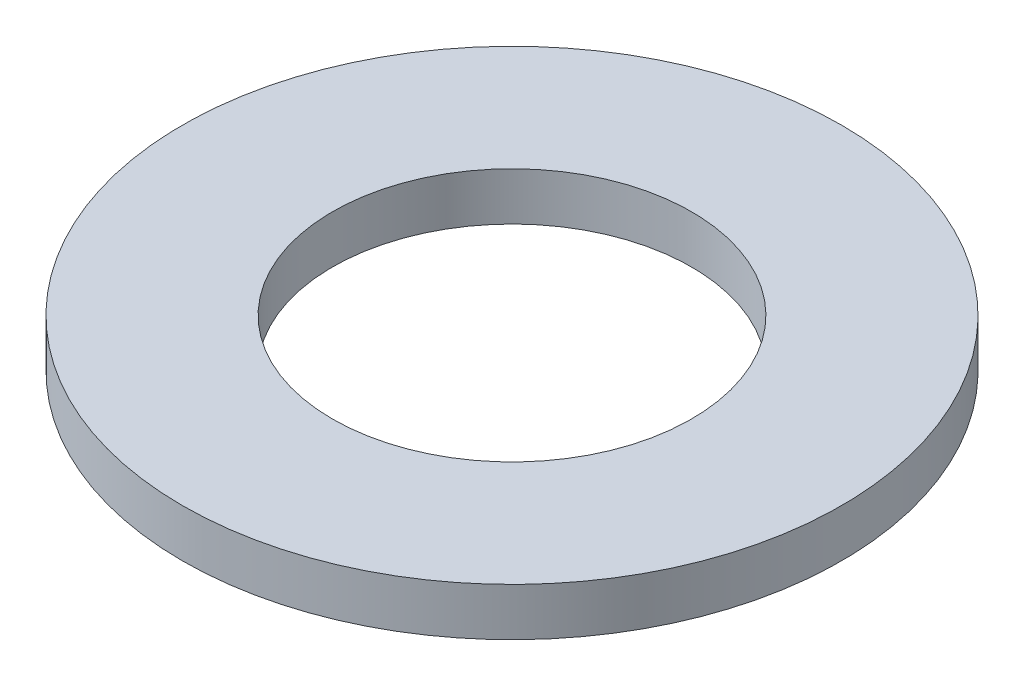
from build123d import *

# Parameters (mm, degrees)
SKETCH1_R           = 5.9436
BOSS_EXTRUDE1_DEPTH = 0.8636
SKETCH5_R           = 3.2385
CUT_EXTRUDE1_DEPTH  = 1.8636


with BuildPart() as part:
    # Sketch1 → Boss-Extrude1 (new body)
    with BuildSketch(Plane(origin=(0, 0, 0), x_dir=(1, 0, 0), z_dir=(0, 1, 0))):
        Circle(SKETCH1_R)
    extrude(amount=BOSS_EXTRUDE1_DEPTH)

    # Sketch5 → Cut-Extrude1 (cut, through all)
    with BuildSketch(Plane(origin=(0, 0.8636, 0), x_dir=(-1, 0, 0), z_dir=(0, 1, 0))):
        Circle(SKETCH5_R)
    extrude(amount=-CUT_EXTRUDE1_DEPTH, mode=Mode.SUBTRACT)


solid = part.part
